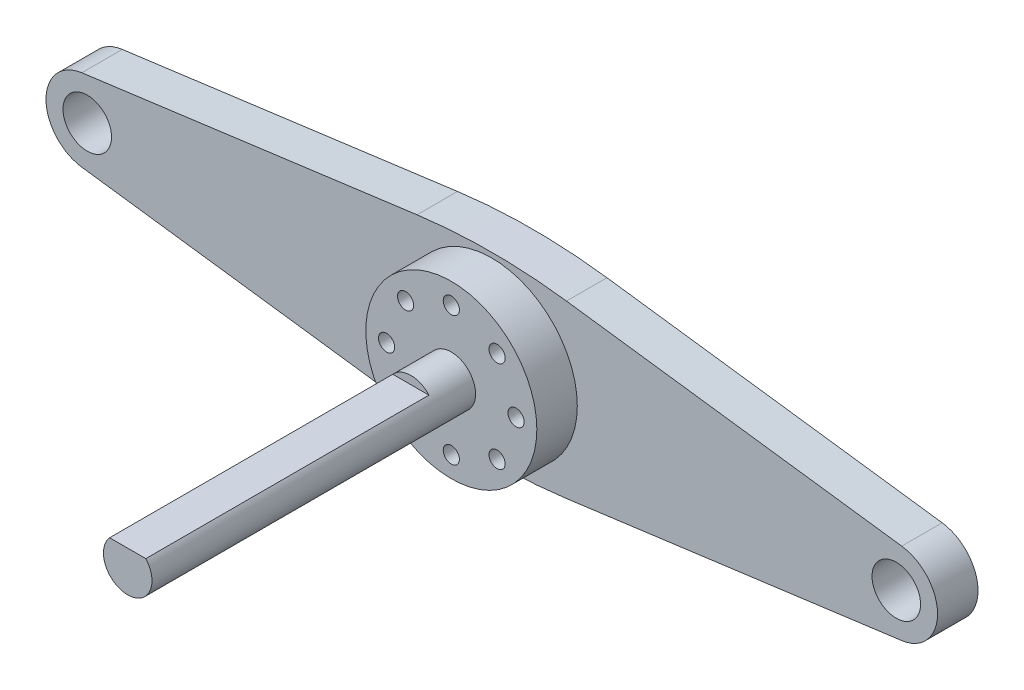
from build123d import *

# Parameters (mm, degrees)
SZKIC1_R                    = 3
SZKIC1_R_2                  = 1
DODANIE_WYCI_GNI_CIE1_DEPTH = 5
SZKIC1_3_R                  = 10.570763761
SZKIC1_3_R_2                = 1
DODANIE_WYCI_GNI_CIE2_DEPTH = 10
DODANIE_WYCI_GNI_CIE3_DEPTH = 50
SZKIC1_5_R                  = 3
DODANIE_WYCI_GNI_CIE4_DEPTH = 15


with BuildPart() as part:
    # Szkic1 → Dodanie-wyci_gni_cie1 (new body)
    with BuildSketch(Plane.XY):
        with BuildLine():
            Line((-9.235111676, 10.570763761), (-50.67287635, 5.055665151))
            ThreePointArc((-50.67287635, 5.055665151), (-55.100246338, 0), (-50.67287635, -5.055665151))
            Line((-50.67287635, -5.055665151), (-9.235111676, -10.570763761))
            ThreePointArc((-9.235111676, -10.570763761), (0, -11.182632843), (9.235111676, -10.570763761))
            Line((9.235111676, -10.570763761), (50.67287635, -5.055665151))
            ThreePointArc((50.67287635, -5.055665151), (55.100246338, 0), (50.67287635, 5.055665151))
            Line((50.67287635, 5.055665151), (9.235111676, 10.570763761))
            ThreePointArc((9.235111676, 10.570763761), (0, 11.182632843), (-9.235111676, 10.570763761))
        make_face()
        with Locations((-50, 0)):
            Circle(SZKIC1_R, mode=Mode.SUBTRACT)
        with Locations((50, 0)):
            Circle(SZKIC1_R, mode=Mode.SUBTRACT)
        with Locations((0, 8)):
            Circle(SZKIC1_R_2, mode=Mode.SUBTRACT)
        with Locations((0, -8)):
            Circle(SZKIC1_R_2, mode=Mode.SUBTRACT)
        with Locations((-5.656854249, -5.656854249)):
            Circle(SZKIC1_R_2, mode=Mode.SUBTRACT)
        with Locations((-8, 0)):
            Circle(SZKIC1_R_2, mode=Mode.SUBTRACT)
        with Locations((5.656854249, -5.656854249)):
            Circle(SZKIC1_R_2, mode=Mode.SUBTRACT)
        with Locations((8, 0)):
            Circle(SZKIC1_R_2, mode=Mode.SUBTRACT)
        with Locations((-5.656854249, 5.656854249)):
            Circle(SZKIC1_R_2, mode=Mode.SUBTRACT)
        with Locations((5.656854249, 5.656854249)):
            Circle(SZKIC1_R_2, mode=Mode.SUBTRACT)
    extrude(amount=DODANIE_WYCI_GNI_CIE1_DEPTH)

    # Szkic1_3 → Dodanie-wyci_gni_cie2 (add)
    with BuildSketch(Plane.XY):
        Circle(SZKIC1_3_R)
        with Locations((0, -8)):
            Circle(SZKIC1_3_R_2, mode=Mode.SUBTRACT)
        with Locations((-5.656854249, -5.656854249)):
            Circle(SZKIC1_3_R_2, mode=Mode.SUBTRACT)
        with Locations((-8, 0)):
            Circle(SZKIC1_3_R_2, mode=Mode.SUBTRACT)
        with BuildLine():
            ThreePointArc((-2.236067977, 2), (0, 3), (2.236067977, 2))
            ThreePointArc((2.236067977, 2), (2.802517077, 1.070466269), (3, 0))
            ThreePointArc((3, 0), (-1.070466269, -2.802517077), (-2.236067977, 2))
        make_face(mode=Mode.SUBTRACT)
        with Locations((5.656854249, -5.656854249)):
            Circle(SZKIC1_3_R_2, mode=Mode.SUBTRACT)
        with Locations((8, 0)):
            Circle(SZKIC1_3_R_2, mode=Mode.SUBTRACT)
        with Locations((-5.656854249, 5.656854249)):
            Circle(SZKIC1_3_R_2, mode=Mode.SUBTRACT)
        with Locations((5.656854249, 5.656854249)):
            Circle(SZKIC1_3_R_2, mode=Mode.SUBTRACT)
        with Locations((0, 8)):
            Circle(SZKIC1_3_R_2, mode=Mode.SUBTRACT)
    extrude(amount=DODANIE_WYCI_GNI_CIE2_DEPTH)

    # Szkic1_4 → Dodanie-wyci_gni_cie3 (add)
    with BuildSketch(Plane.XY):
        with BuildLine():
            ThreePointArc((3, 0), (2.802517077, 1.070466269), (2.236067977, 2))
            Line((2.236067977, 2), (-2.236067977, 2))
            ThreePointArc((-2.236067977, 2), (-1.070466269, -2.802517077), (3, 0))
        make_face()
    extrude(amount=DODANIE_WYCI_GNI_CIE3_DEPTH)

    # Szkic1_5 → Dodanie-wyci_gni_cie4 (add)
    with BuildSketch(Plane.XY):
        Circle(SZKIC1_5_R)
    extrude(amount=DODANIE_WYCI_GNI_CIE4_DEPTH)


solid = part.part
